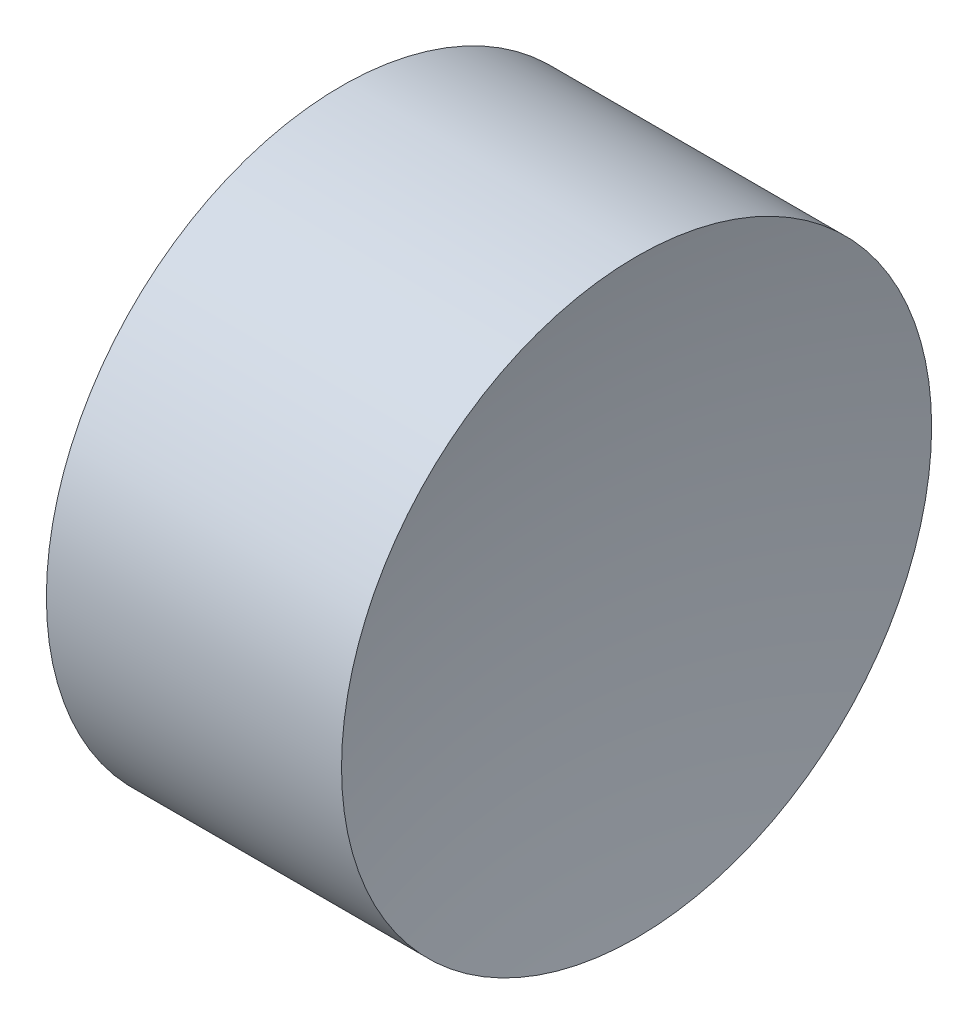
from build123d import *


with BuildPart() as part:
    # 草图1 → 旋转1 (revolve)
    with BuildSketch(Plane.XY, mode=Mode.PRIVATE) as revolve_1_sk:
        with BuildLine():
            Line((11.080595085, 6.515563046), (11.080595085, 8.515563046))
            Line((11.080595085, 8.515563046), (13.081354894, 8.515563046))
            ThreePointArc((13.081354894, 8.515563046), (12.915952125, 7.521636464), (12.860595085, 6.515563046))
            Line((12.860595085, 6.515563046), (11.080595085, 6.515563046))
        make_face()
    revolve(revolve_1_sk.sketch.rotate(Axis((10.578235961, 6.515563046, 0), (1, 0, 0)), 180), axis=Axis((10.578235961, 6.515563046, 0), (1, 0, 0)))  # turned: the seam where the file's is


solid = part.part
